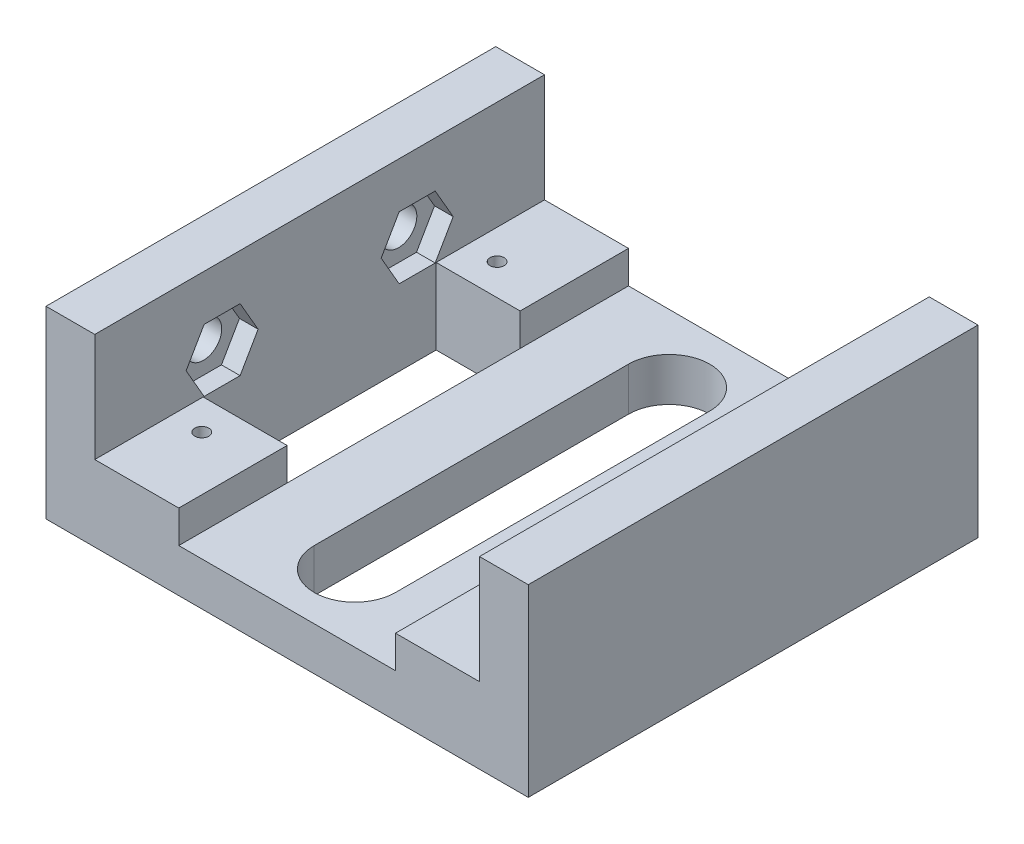
from build123d import *

# Parameters (mm, degrees)
SKETCH1_W                = 89
SKETCH1_H                = 83
SKETCH1_R                = 1.3
MAIN_BODY_DEPTH          = 14
SKETCH2_W                = 40
SKETCH2_H                = 83
SCREW_GROOVE_DEPTH       = 6
SKETCH4_W                = 9
SKETCH4_H                = 83
MOUNT_LIFT_DEPTH         = 20
MOUNT_START              = -5.55625
MOUNT_NUTS_DEPTH         = 18.94375
F_9_32_MOUNT_HOLES_REACH = 7.556
SKETCH5_R                = 3.3734375
SKETCH8_W                = 15.5
SKETCH8_H                = 43
MIDDLE_CUT_DEPTH         = 14


with BuildPart() as part:
    # Sketch1 → Main Body (new body)
    with BuildSketch(Plane(origin=(0, 0, 0), x_dir=(1, 0, 0), z_dir=(0, 1, 0))):
        with Locations((0, 41.5)):
            Rectangle(SKETCH1_W, SKETCH1_H)
        with Locations((-30, 14.25)):
            Circle(SKETCH1_R, mode=Mode.SUBTRACT)
        with Locations((30, 14.25)):
            Circle(SKETCH1_R, mode=Mode.SUBTRACT)
        with BuildLine():
            Line((-7.5, 12.5), (-7.5, 70.5))
            ThreePointArc((-7.5, 70.5), (0, 78), (7.5, 70.5))
            Line((7.5, 70.5), (7.5, 12.5))
            ThreePointArc((7.5, 12.5), (0, 5), (-7.5, 12.5))
        make_face(mode=Mode.SUBTRACT)
        with Locations((-30, 68.75)):
            Circle(SKETCH1_R, mode=Mode.SUBTRACT)
        with Locations((30, 68.75)):
            Circle(SKETCH1_R, mode=Mode.SUBTRACT)
    extrude(amount=MAIN_BODY_DEPTH)

    # Sketch2 → Screw Groove (cut)
    with BuildSketch(Plane(origin=(0, 14, 0), x_dir=(1, 0, 0), z_dir=(0, 1, 0))):
        with Locations((0, 41.5)):
            Rectangle(SKETCH2_W, SKETCH2_H)
    extrude(amount=-SCREW_GROOVE_DEPTH, mode=Mode.SUBTRACT)

    # Sketch4 → Mount Lift (add)
    with BuildSketch(Plane(origin=(0, 14, 0), x_dir=(1, 0, 0), z_dir=(0, 1, 0))):
        with Locations((-40, 41.5)):
            Rectangle(SKETCH4_W, SKETCH4_H)
        with Locations((40, 41.5)):
            Rectangle(SKETCH4_W, SKETCH4_H)
    extrude(amount=MOUNT_LIFT_DEPTH)

    # Sketch6 → Mount Nuts (cut)
    with BuildSketch(Plane.ZY.offset(44.5).offset(MOUNT_START)):
        Polygon((-52.855059246, 19.7546875), (-56.177529623, 25.509375), (-62.822470377, 25.509375), (-66.144940754, 19.7546875), (-62.822470377, 14), (-56.177529623, 14), align=None)
        Polygon((-16.855059246, 19.7546875), (-20.177529623, 25.509375), (-26.822470377, 25.509375), (-30.144940754, 19.7546875), (-26.822470377, 14), (-20.177529623, 14), align=None)
    extrude(amount=-MOUNT_NUTS_DEPTH, mode=Mode.SUBTRACT)

    # Sketch5 → 9/32 Mount Holes (cut, up to next)
    with BuildSketch(Plane.ZY.offset(38.94375), mode=Mode.PRIVATE) as f_9_32_mount_holes_sk1:
        with Locations((-59.5, 19.7546875)):
            Circle(SKETCH5_R)
    f_9_32_mount_holes_tool1 = extrude(f_9_32_mount_holes_sk1.sketch, amount=F_9_32_MOUNT_HOLES_REACH, mode=Mode.PRIVATE) & part.part
    add(f_9_32_mount_holes_tool1.solids().sort_by_distance((-38.94375, 19.754688, -59.5))[0], mode=Mode.SUBTRACT)
    # Sketch5 → 9/32 Mount Holes (cut, up to next)
    with BuildSketch(Plane.ZY.offset(38.94375), mode=Mode.PRIVATE) as f_9_32_mount_holes_sk2:
        with Locations((-23.5, 19.7546875)):
            Circle(SKETCH5_R)
    f_9_32_mount_holes_tool2 = extrude(f_9_32_mount_holes_sk2.sketch, amount=F_9_32_MOUNT_HOLES_REACH, mode=Mode.PRIVATE) & part.part
    add(f_9_32_mount_holes_tool2.solids().sort_by_distance((-38.94375, 19.754688, -23.5))[0], mode=Mode.SUBTRACT)

    # Sketch8 → Middle Cut (cut)
    with BuildSketch(Plane(origin=(0, 14, 0), x_dir=(1, 0, 0), z_dir=(0, 1, 0))):
        with Locations((-27.75, 41.5)):
            Rectangle(SKETCH8_W, SKETCH8_H)
        with Locations((27.75, 41.5)):
            Rectangle(SKETCH8_W, SKETCH8_H)
    extrude(amount=-MIDDLE_CUT_DEPTH, mode=Mode.SUBTRACT)


solid = part.part
